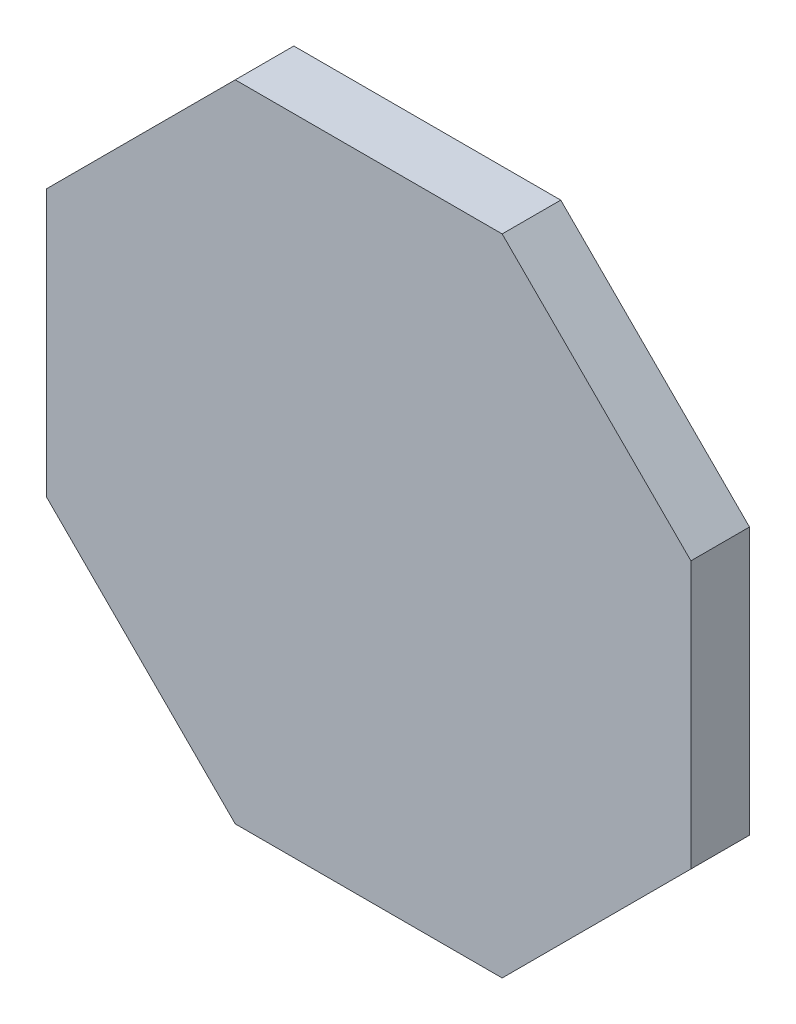
from build123d import *

# Parameters (mm, degrees)
BOSS_EXTRUDE1_DEPTH = 10


with BuildPart() as part:
    # Sketch1 → Boss-Extrude1 (new body)
    with BuildSketch(Plane.XY):
        Polygon((55, 22.781745931), (22.781745931, 55), (-22.781745931, 55), (-55, 22.781745931), (-55, -22.781745931), (-22.781745931, -55), (22.781745931, -55), (55, -22.781745931), align=None)
    extrude(amount=BOSS_EXTRUDE1_DEPTH)


solid = part.part
